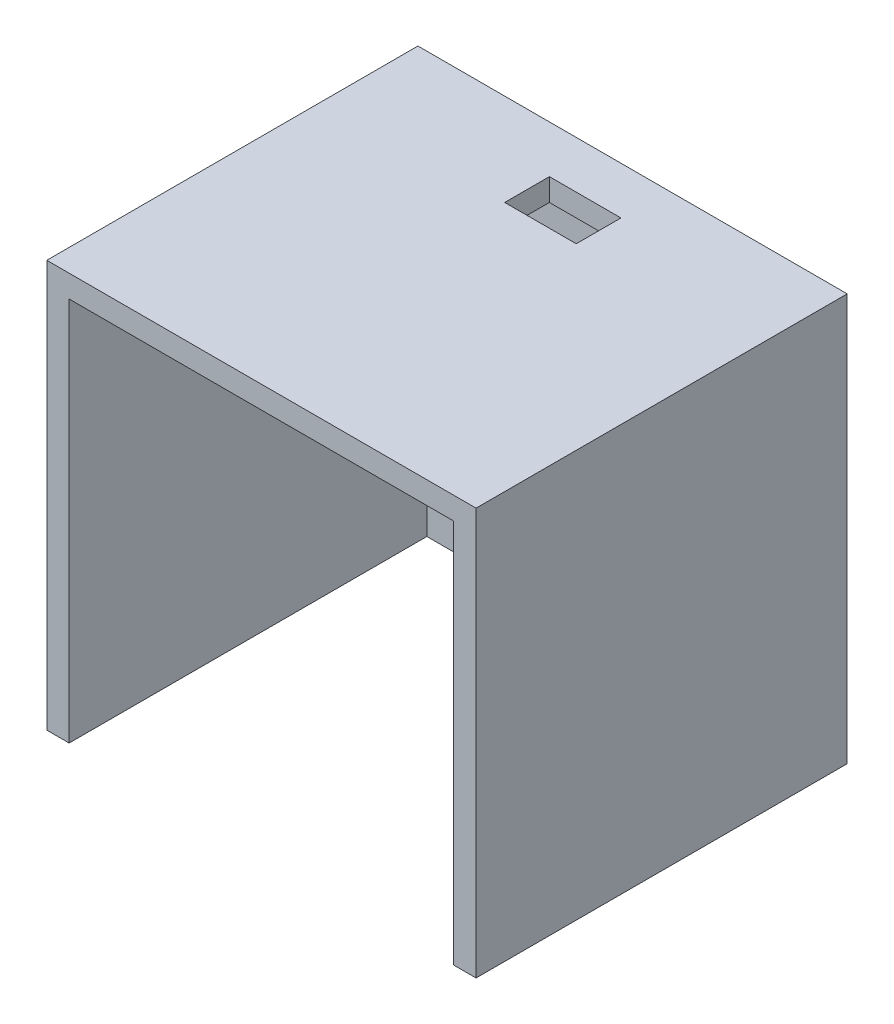
from build123d import *

# Parameters (mm, degrees)
ESQUISSE1_W             = 43
ESQUISSE1_H             = 43
BOSS_EXTRU_1_DEPTH      = 40
ESQUISSE2_W             = 48
ESQUISSE2_H             = 48
BOSS_EXTRU_2_DEPTH      = 1.5
ENL_V_MAT_EXTRU_3_REACH = 50
ESQUISSE5_W             = 8
ESQUISSE5_H             = 5
ENL_V_MAT_EXTRU_4_REACH = 43.5
ESQUISSE6_W             = 54.781223227
ESQUISSE6_H             = 3.078773465


with BuildPart() as part:
    # Esquisse1 → Boss.-Extru.1 (new body)
    with BuildSketch(Plane.XY):
        Polygon((-2.5, 43), (-2.5, -2.5), (0, -2.5), (45.5, -2.5), (45.5, 43), (45.5, 45.5), (-2.5, 45.5), align=None)
        with Locations((21.5, 21.5)):
            Rectangle(ESQUISSE1_W, ESQUISSE1_H, mode=Mode.SUBTRACT)
    extrude(amount=BOSS_EXTRU_1_DEPTH)

    # Esquisse2 → Boss.-Extru.2 (add)
    with BuildSketch(Plane.XY):
        with Locations((21.5, 21.5)):
            Rectangle(ESQUISSE2_W, ESQUISSE2_H)
    extrude(amount=-BOSS_EXTRU_2_DEPTH)

    # Esquisse5 → Enlèv. mat.-Extru.3 (cut, up to next)
    with BuildSketch(Plane(origin=(0, 45.5, 0), x_dir=(1, 0, 0), z_dir=(0, 1, 0)), mode=Mode.PRIVATE) as enl_v_mat_extru_3_sk1:
        with Locations((21.5, -6.3)):
            Rectangle(ESQUISSE5_W, ESQUISSE5_H)
    enl_v_mat_extru_3_tool1 = extrude(enl_v_mat_extru_3_sk1.sketch, amount=-ENL_V_MAT_EXTRU_3_REACH, mode=Mode.PRIVATE) & part.part
    add(enl_v_mat_extru_3_tool1.solids().sort_by_distance((21.5, 45.5, 6.3))[0], mode=Mode.SUBTRACT)

    # Esquisse6 → Enlèv. mat.-Extru.4 (cut, up to next)
    with BuildSketch(Plane.XY.offset(40), mode=Mode.PRIVATE) as enl_v_mat_extru_4_sk1:
        with Locations((23.162986277, -1.539386733)):
            Rectangle(ESQUISSE6_W, ESQUISSE6_H)
    enl_v_mat_extru_4_tool1 = extrude(enl_v_mat_extru_4_sk1.sketch, amount=-ENL_V_MAT_EXTRU_4_REACH, mode=Mode.PRIVATE) & part.part
    add(enl_v_mat_extru_4_tool1.solids().sort_by_distance((23.162986, -1.539387, 40))[0], mode=Mode.SUBTRACT)


solid = part.part
